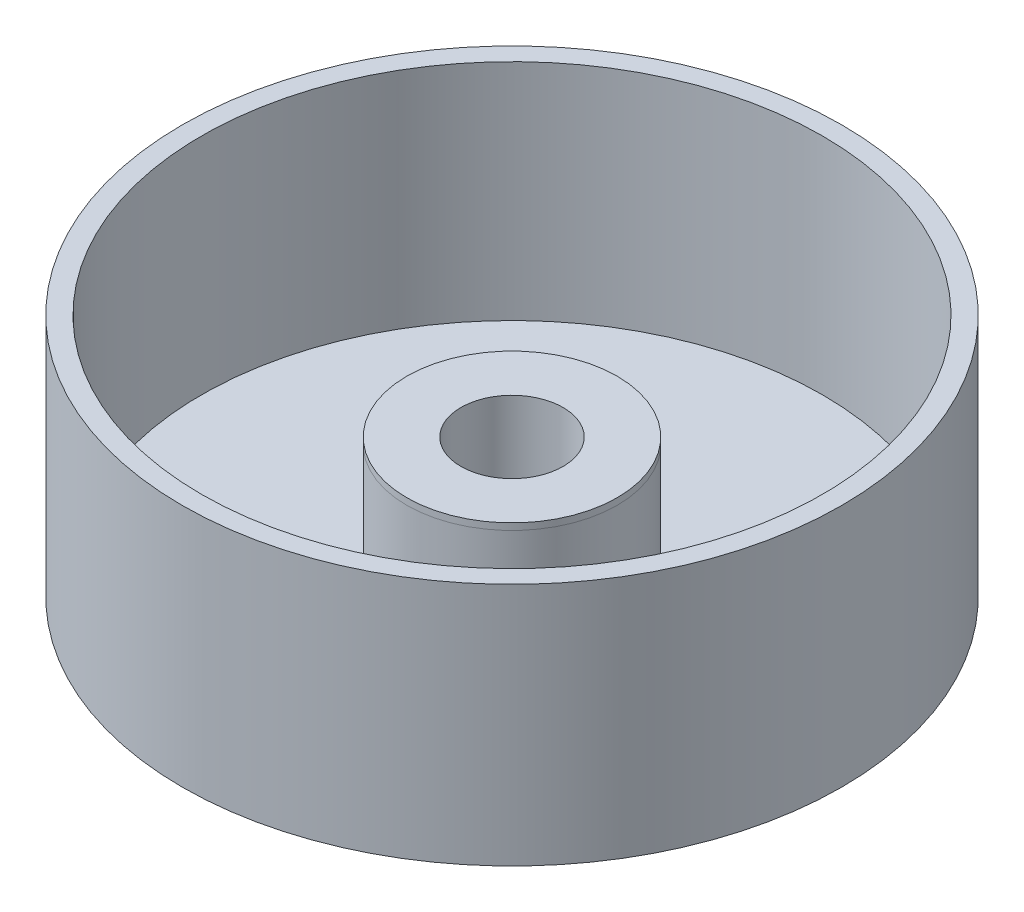
from build123d import *

# Parameters (mm, degrees)
SKETCH1_R                      = 15.958
SHAFTHOLDERNEARMOTOR_DEPTH     = 1
SKETCH2_R                      = 3.4
CUT_EXTRUDE1_DEPTH             = 16.85
SKETCH10_R                     = 50
BOSS_EXTRUDE4_DEPTH            = 20
SKETCH12_R                     = 47.082764373
SKETCH12_R_2                   = 15.95790089
CUTTOREMVEEXCESSMATERIAL_DEPTH = 17
SKETCH13_R                     = 50
SKETCH13_R_2                   = 47.082764373
BOSS_EXTRUDE5_DEPTH            = 17
SKETCH32_R                     = 7.75
CUT_EXTRUDE2_DEPTH             = 22


with BuildPart() as part:
    # Sketch1 → ShaftHolderNearMotor (new body)
    with BuildSketch(Plane(origin=(0, 0, 0), x_dir=(1, 0, 0), z_dir=(0, 1, 0))):
        Circle(SKETCH1_R)
    extrude(amount=SHAFTHOLDERNEARMOTOR_DEPTH)

    # Sketch2 → Cut-Extrude1 (cut)
    with BuildSketch(Plane(origin=(0, 1, 0), x_dir=(1, 0, 0), z_dir=(0, 1, 0))):
        Circle(SKETCH2_R)
    extrude(amount=-CUT_EXTRUDE1_DEPTH, mode=Mode.SUBTRACT)

    # Sketch10 → Boss-Extrude4 (add)
    with BuildSketch(Plane.XZ):
        Circle(SKETCH10_R)
    extrude(amount=BOSS_EXTRUDE4_DEPTH)

    # Sketch12 → CutToRemveExcessMaterial (cut)
    with BuildSketch(Plane(origin=(0, 0, 0), x_dir=(1, 0, 0), z_dir=(0, 1, 0))):
        Circle(SKETCH12_R)
        Circle(SKETCH12_R_2, mode=Mode.SUBTRACT)
    extrude(amount=-CUTTOREMVEEXCESSMATERIAL_DEPTH, mode=Mode.SUBTRACT)

    # Sketch13 → Boss-Extrude5 (add)
    with BuildSketch(Plane(origin=(0, 0, 0), x_dir=(1, 0, 0), z_dir=(0, 1, 0))):
        Circle(SKETCH13_R)
        Circle(SKETCH13_R_2, mode=Mode.SUBTRACT)
    extrude(amount=BOSS_EXTRUDE5_DEPTH)

    # Sketch32 → Cut-Extrude2 (cut, through all)
    with BuildSketch(Plane(origin=(0, 1, 0), x_dir=(1, 0, 0), z_dir=(0, 1, 0))):
        Circle(SKETCH32_R)
    extrude(amount=-CUT_EXTRUDE2_DEPTH, mode=Mode.SUBTRACT)


solid = part.part
